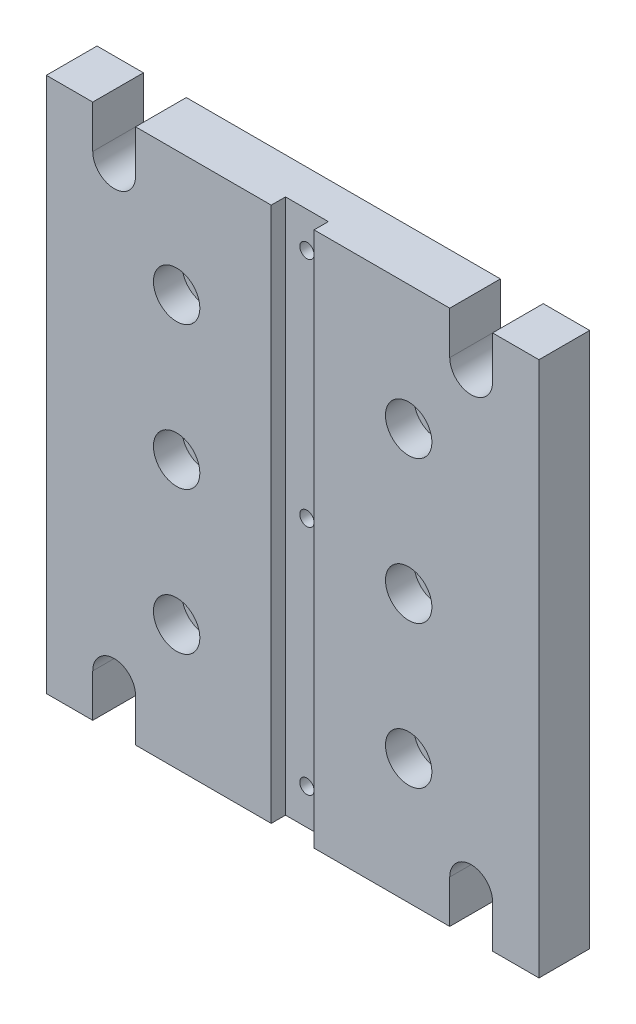
from build123d import *

# Parameters (mm, degrees)
CROQUIS1_R              = 4.25
CROQUIS1_R_2            = 2
SALIENTE_EXTRUIR1_DEPTH = 14.2
CROQUIS2_W              = 12
CROQUIS2_H              = 162.31128511
CORTAR_EXTRUIR1_DEPTH   = 4
CROQUIS3_R              = 6.5
CORTAR_EXTRUIR2_DEPTH   = 8


with BuildPart() as part:
    # Croquis1 → Saliente-Extruir1 (new body)
    with BuildSketch(Plane.XY):
        with BuildLine():
            Line((69, -75), (56, -75))
            Line((56, -75), (56, -63))
            ThreePointArc((56, -63), (50, -57), (44, -63))
            Line((44, -63), (44, -75))
            Line((44, -75), (-44, -75))
            Line((-44, -75), (-44, -63))
            ThreePointArc((-44, -63), (-50, -57), (-56, -63))
            Line((-56, -63), (-56, -75))
            Line((-56, -75), (-69, -75))
            Line((-69, -75), (-69, 75))
            Line((-69, 75), (-56, 75))
            Line((-56, 75), (-56, 63))
            ThreePointArc((-56, 63), (-50, 57), (-44, 63))
            Line((-44, 63), (-44, 75))
            Line((-44, 75), (44, 75))
            Line((44, 75), (44, 63))
            ThreePointArc((44, 63), (50, 57), (56, 63))
            Line((56, 63), (56, 75))
            Line((56, 75), (69, 75))
            Line((69, 75), (69, -75))
        make_face()
        with Locations((-32.5, 40)):
            Circle(CROQUIS1_R, mode=Mode.SUBTRACT)
        with Locations((-32.5, 0)):
            Circle(CROQUIS1_R, mode=Mode.SUBTRACT)
        with Locations((-32.5, -40)):
            Circle(CROQUIS1_R, mode=Mode.SUBTRACT)
        with Locations((32.5, 40)):
            Circle(CROQUIS1_R, mode=Mode.SUBTRACT)
        with Locations((32.5, 0)):
            Circle(CROQUIS1_R, mode=Mode.SUBTRACT)
        with Locations((32.5, -40)):
            Circle(CROQUIS1_R, mode=Mode.SUBTRACT)
        with Locations((0, 65)):
            Circle(CROQUIS1_R_2, mode=Mode.SUBTRACT)
        Circle(CROQUIS1_R_2, mode=Mode.SUBTRACT)
        with Locations((0, -65)):
            Circle(CROQUIS1_R_2, mode=Mode.SUBTRACT)
    extrude(amount=SALIENTE_EXTRUIR1_DEPTH)

    # Croquis2 → Cortar-Extruir1 (cut)
    with BuildSketch(Plane.XY.offset(14.2)):
        with Locations((0, -0.838384737)):
            Rectangle(CROQUIS2_W, CROQUIS2_H)
    extrude(amount=-CORTAR_EXTRUIR1_DEPTH, mode=Mode.SUBTRACT)

    # Croquis3 → Cortar-Extruir2 (cut)
    with BuildSketch(Plane.XY.offset(14.2)):
        with Locations((-32.5, 40)):
            Circle(CROQUIS3_R)
        with Locations((-32.5, 0)):
            Circle(CROQUIS3_R)
        with Locations((-32.5, -40)):
            Circle(CROQUIS3_R)
        with Locations((32.5, 40)):
            Circle(CROQUIS3_R)
        with Locations((32.5, 0)):
            Circle(CROQUIS3_R)
        with Locations((32.5, -40)):
            Circle(CROQUIS3_R)
    extrude(amount=-CORTAR_EXTRUIR2_DEPTH, mode=Mode.SUBTRACT)


solid = part.part
